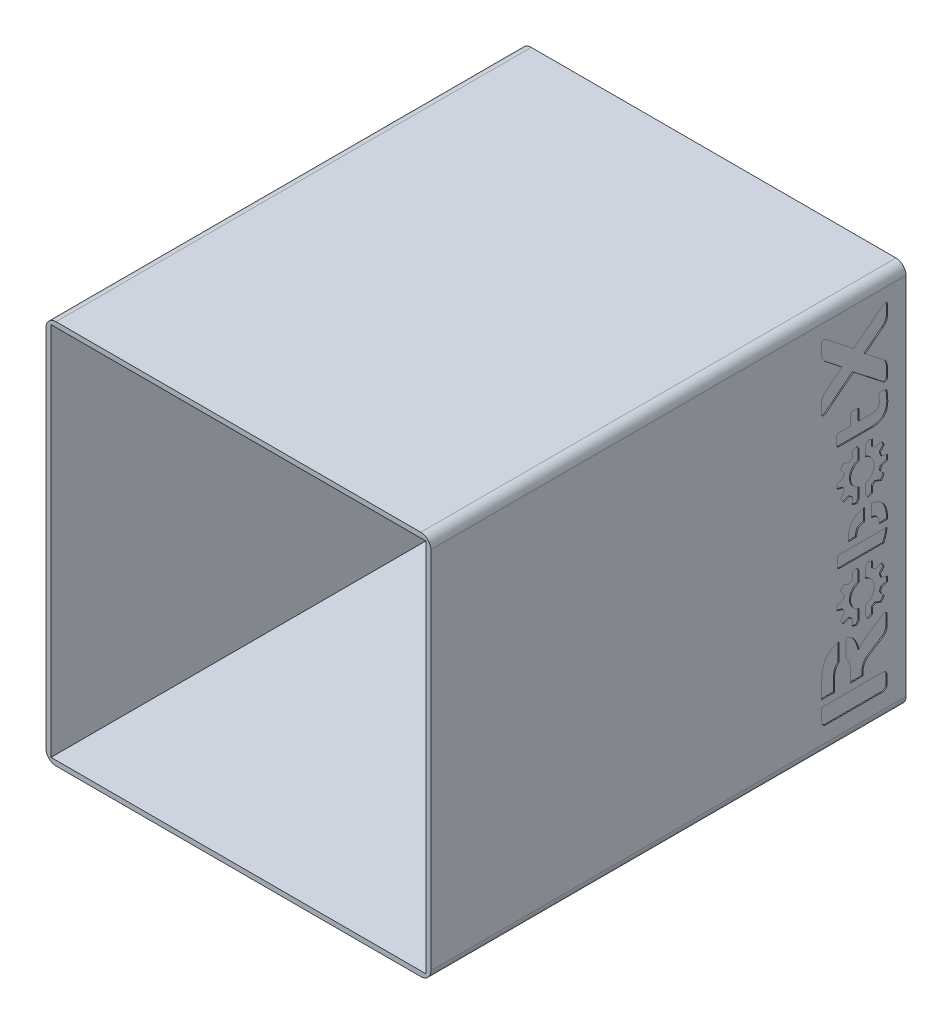
from build123d import *

# Parameters (mm, degrees)
SKETCH_1_W          = 115
SKETCH_1_H          = 115
EXTRUDE_1_DEPTH     = 2
SKETCH_2_W          = 115
SKETCH_2_H          = 115
SKETCH_2_W_2        = 112
SKETCH_2_H_2        = 112
EXTRUDE_2_DEPTH     = 140
FILLET_1_R          = 3
CUT_EXTRUDE_1_DEPTH = 0.3


with BuildPart() as part:
    # Эскиз1 → Бобышка-Вытянуть1 (new body)
    with BuildSketch(Plane.XY):
        Rectangle(SKETCH_1_W, SKETCH_1_H)
    extrude(amount=EXTRUDE_1_DEPTH)

    # Эскиз2 → Бобышка-Вытянуть2 (add)
    with BuildSketch(Plane.XY.offset(2)):
        Rectangle(SKETCH_2_W, SKETCH_2_H)
        Rectangle(SKETCH_2_W_2, SKETCH_2_H_2, mode=Mode.SUBTRACT)
    extrude(amount=EXTRUDE_2_DEPTH)

    # Скругление1
    fillet_1_edges = [part.edges().sort_by_distance(p)[0] for p in [
        (57.5, -57.5, 71),
        (-57.5, -57.5, 71),
        (-57.5, 57.5, 71),
        (57.5, 57.5, 71),
    ]]
    fillet(fillet_1_edges, radius=FILLET_1_R)

    # Эскиз3 → Вырез-Вытянуть1 (cut)
    with BuildSketch(Plane(origin=(57.5, 0, 0), x_dir=(0, 0, -1), z_dir=(1, 0, 0))):
        with BuildLine():
            Line((-11.080562605, -38.273823271), (-6.969637498, -35.678999813))
            ThreePointArc((-6.969637498, -35.678999813), (-6.018819324, -34.670187292), (-5.673247782, -33.327675388))
            Line((-5.673247782, -33.327675388), (-5.673247782, -30.246101875))
            ThreePointArc((-5.673247782, -30.246101875), (-6.015820413, -29.666035895), (-6.689196543, -29.685964145))
            Line((-6.689196543, -29.685964145), (-10.877080493, -32.329364165))
            add(Edge.make_bspline(
                [(-10.877080493, -32.329364165), (-12.633193827, -33.437826119), (-13.609384525, -34.270049482), (-14.029837494, -35.409873863)],
                knots=[0.333333333, 0.333333333, 0.333333333, 0.333333333, 0.388888889, 0.388888889, 0.388888889, 0.388888889], degree=3))
            add(Edge.make_bspline(
                [(-17.988875381, -30.371318738), (-16.275658731, -30.693081088), (-14.839974018, -31.958272247), (-14.029837494, -35.409873863)],
                knots=[0.637571884, 0.637571884, 0.637571884, 0.637571884, 1, 1, 1, 1], degree=3))
            Line((-17.988875381, -30.371318738), (-17.988875381, -35.769994881))
            add(Edge.make_bspline(
                [(-17.988875381, -35.769994881), (-17.227109916, -36.290354954), (-16.637413678, -37.373701833), (-16.637413678, -38.952390091)],
                knots=[0.645896495, 0.645896495, 0.645896495, 0.645896495, 1, 1, 1, 1], degree=3))
            Line((-16.637413678, -38.952390091), (-16.637413678, -42.740580699))
            Line((-16.637413678, -42.740580699), (-12.809082226, -42.740580699))
            Line((-12.809082226, -42.740580699), (-12.809082226, -41.408922505))
            ThreePointArc((-12.809082226, -41.408922505), (-12.34832017, -39.618906633), (-11.080562605, -38.273823271))
        make_face()
        with BuildLine():
            Line((-25.180573226, -37.377711774), (-25.180573226, -42.740580699))
            Line((-25.180573226, -42.740580699), (-21.340337084, -42.740580699))
            Line((-21.340337084, -42.740580699), (-21.340337084, -38.952390091))
            add(Edge.make_bspline(
                [(-21.340337084, -38.952390091), (-21.340337084, -37.193873781), (-20.750640847, -36.121732081), (-19.988875381, -35.668319344)],
                knots=[0, 0, 0, 0, 0.354103505, 0.354103505, 0.354103505, 0.354103505], degree=3))
            Line((-19.988875381, -35.668319344), (-19.988875381, -30.34974922))
            add(Edge.make_bspline(
                [(-25.180573226, -37.377711774), (-25.180573226, -32.621234164), (-22.556371402, -30.71701754), (-19.988875381, -30.34974922)],
                knots=[0, 0, 0, 0, 0.50309199, 0.50309199, 0.50309199, 0.50309199], degree=3))
        make_face()
        with BuildLine():
            Line((-23.900284426, -49.860907913), (-6.953536582, -49.860907913))
            ThreePointArc((-6.953536582, -49.860907913), (-6.04823569, -49.485920005), (-5.673247782, -48.580619113))
            Line((-5.673247782, -48.580619113), (-5.673247782, -46.020869499))
            ThreePointArc((-5.673247782, -46.020869499), (-6.04823569, -45.115568606), (-6.953536582, -44.740580699))
            Line((-6.953536582, -44.740580699), (-25.180573226, -44.740580699))
            Line((-25.180573226, -44.740580699), (-25.180573226, -48.580619113))
            ThreePointArc((-25.180573226, -48.580619113), (-24.805585319, -49.485920005), (-23.900284426, -49.860907913))
        make_face()
        with BuildLine():
            Line((-5.630369109, -7.828075043), (-19.895761032, -7.828075043))
            add(Edge.make_bspline(
                [(-19.895761032, -7.828075043), (-20.259172738, -7.828075043), (-20.537907428, -8.103287703), (-20.537907428, -8.463152663)],
                knots=[0.545454545, 0.545454545, 0.545454545, 0.545454545, 0.636363636, 0.636363636, 0.636363636, 0.636363636], degree=3))
            Line((-20.537907428, -8.463152663), (-20.537907428, -10.770638423))
            add(Edge.make_bspline(
                [(-20.537907428, -10.770638423), (-20.537907428, -11.130503383), (-20.259172738, -11.405716043), (-19.895761032, -11.405716043)],
                knots=[0.727272727, 0.727272727, 0.727272727, 0.727272727, 0.818181818, 0.818181818, 0.818181818, 0.818181818], degree=3))
            Line((-19.895761032, -11.405716043), (-6.65077794, -11.405716043))
            add(Edge.make_bspline(
                [(-6.65077794, -11.405716043), (-6.215461864, -10.651151236), (-5.829871458, -9.269987246), (-5.630369109, -7.828075043)],
                knots=[0, 0, 0, 0, 0.06231394, 0.06231394, 0.06231394, 0.06231394], degree=3))
        make_face()
        with BuildLine():
            Line((-6.302331772, 28.133346575), (-7.41919838, 28.133346575))
            add(Edge.make_bspline(
                [(-7.41919838, 28.133346575), (-7.784340206, 28.133346575), (-8.063556858, 27.854092849), (-8.063556858, 27.488988097)],
                knots=[0.1, 0.1, 0.1, 0.1, 0.15, 0.15, 0.15, 0.15], degree=3))
            Line((-8.063556858, 27.488988097), (-8.063556858, 27.102380425))
            add(Edge.make_bspline(
                [(-8.063556858, 27.102380425), (-8.063556858, 26.629847579), (-7.934675276, 26.221749345), (-7.934675276, 25.663316041)],
                knots=[0.2, 0.2, 0.2, 0.2, 0.25, 0.25, 0.25, 0.25], degree=3))
            add(Edge.make_bspline(
                [(-7.934675276, 25.663316041), (-7.934675276, 24.567915279), (-8.707915336, 23.816165781), (-10.168470282, 23.816165781)],
                knots=[0.25, 0.25, 0.25, 0.25, 0.3, 0.3, 0.3, 0.3], degree=3))
            Line((-10.168470282, 23.816165781), (-14.01311823, 23.816165781))
            Line((-14.01311823, 23.816165781), (-14.01311823, 26.737238599))
            add(Edge.make_bspline(
                [(-14.01311823, 26.737238599), (-14.01311823, 27.102380425), (-14.292334882, 27.381597077), (-14.657476708, 27.381597077)],
                knots=[0.4, 0.4, 0.4, 0.4, 0.45, 0.45, 0.45, 0.45], degree=3))
            Line((-14.657476708, 27.381597077), (-15.903224898, 27.381597077))
            add(Edge.make_bspline(
                [(-15.903224898, 27.381597077), (-16.268366724, 27.381597077), (-16.547583376, 27.102380425), (-16.547583376, 26.737238599)],
                knots=[0.5, 0.5, 0.5, 0.5, 0.55, 0.55, 0.55, 0.55], degree=3))
            Line((-16.547583376, 26.737238599), (-16.547583376, 23.816165781))
            Line((-16.547583376, 23.816165781), (-20.066474444, 23.816165781))
            add(Edge.make_bspline(
                [(-20.066474444, 23.816165781), (-20.431628628, 23.816165781), (-20.7144291, 23.536912055), (-20.7144291, 23.171807303)],
                knots=[0.65, 0.65, 0.65, 0.65, 0.7, 0.7, 0.7, 0.7], degree=3))
            Line((-20.7144291, 23.171807303), (-20.7144291, 20.830621277))
            add(Edge.make_bspline(
                [(-20.7144291, 20.830621277), (-20.7144291, 20.465504167), (-20.431628628, 20.186287515), (-20.066474444, 20.186287515)],
                knots=[0.75, 0.75, 0.75, 0.75, 0.8, 0.8, 0.8, 0.8], degree=3))
            Line((-20.066474444, 20.186287515), (-10.168470282, 20.186287515))
            add(Edge.make_bspline(
                [(-10.168470282, 20.186287515), (-6.94669025, 20.186287515), (-5.443191254, 21.689798869), (-5.443191254, 24.696759787)],
                knots=[0.85, 0.85, 0.85, 0.85, 0.9, 0.9, 0.9, 0.9], degree=3))
            add(Edge.make_bspline(
                [(-5.443191254, 24.696759787), (-5.443191254, 25.663316041), (-5.529091712, 26.844617261), (-5.657973294, 27.488988097)],
                knots=[0.9, 0.9, 0.9, 0.9, 1, 1, 1, 1], degree=3))
            add(Edge.make_bspline(
                [(-5.657973294, 27.488988097), (-5.722407906, 27.854092849), (-5.980133996, 28.133346575), (-6.302331772, 28.133346575)],
                knots=[0, 0, 0, 0, 0.05, 0.05, 0.05, 0.05], degree=3))
        make_face()
        with BuildLine():
            Line((-25.2170664, 34.192399827), (-25.2170664, 31.250318409))
            add(Edge.make_bspline(
                [(-25.2170664, 31.250318409), (-25.2170664, 30.521826667), (-24.59595332, 30.241646091), (-23.923480392, 30.773991657)],
                knots=[0.095238095, 0.095238095, 0.095238095, 0.095238095, 0.142857143, 0.142857143, 0.142857143, 0.142857143], degree=3))
            Line((-23.923480392, 30.773991657), (-15.676406166, 37.274534459))
            Line((-15.676406166, 37.274534459), (-6.868908998, 30.381736379))
            add(Edge.make_bspline(
                [(-6.868908998, 30.381736379), (-6.196460786, 29.849341381), (-5.575347706, 30.129559031), (-5.575347706, 30.858063131)],
                knots=[0.238095238, 0.238095238, 0.238095238, 0.238095238, 0.285714286, 0.285714286, 0.285714286, 0.285714286], degree=3))
            Line((-5.575347706, 30.858063131), (-5.575347706, 33.772091889))
            add(Edge.make_bspline(
                [(-5.575347706, 33.772091889), (-5.575347706, 34.892888341), (-6.196460786, 35.621392441), (-6.868908998, 36.153738007)],
                knots=[0.333333333, 0.333333333, 0.333333333, 0.333333333, 0.380952381, 0.380952381, 0.380952381, 0.380952381], degree=3))
            Line((-6.868908998, 36.153738007), (-12.197320216, 40.328653505))
            Line((-12.197320216, 40.328653505), (-6.868908998, 44.503569003))
            add(Edge.make_bspline(
                [(-6.868908998, 44.503569003), (-6.196460786, 45.035964001), (-5.575347706, 45.764455743), (-5.575347706, 46.885252195)],
                knots=[0.476190476, 0.476190476, 0.476190476, 0.476190476, 0.523809524, 0.523809524, 0.523809524, 0.523809524], degree=3))
            Line((-5.575347706, 46.885252195), (-5.575347706, 49.799293311))
            add(Edge.make_bspline(
                [(-5.575347706, 49.799293311), (-5.575347706, 50.527785053), (-6.196460786, 50.807965629), (-6.868908998, 50.275620063)],
                knots=[0.571428571, 0.571428571, 0.571428571, 0.571428571, 0.619047619, 0.619047619, 0.619047619, 0.619047619], degree=3))
            Line((-6.868908998, 50.275620063), (-15.676406166, 43.382809625))
            Line((-15.676406166, 43.382809625), (-23.923480392, 49.883352427))
            add(Edge.make_bspline(
                [(-23.923480392, 49.883352427), (-24.59595332, 50.415710351), (-25.2170664, 50.135529775), (-25.2170664, 49.406988601)],
                knots=[0.714285714, 0.714285714, 0.714285714, 0.714285714, 0.761904762, 0.761904762, 0.761904762, 0.761904762], degree=3))
            Line((-25.2170664, 49.406988601), (-25.2170664, 46.464944257))
            add(Edge.make_bspline(
                [(-25.2170664, 46.464944257), (-25.2170664, 45.344184879), (-24.59595332, 44.615656063), (-23.923480392, 44.083298139)],
                knots=[0.80952381, 0.80952381, 0.80952381, 0.80952381, 0.857142857, 0.857142857, 0.857142857, 0.857142857], degree=3))
            Line((-23.923480392, 44.083298139), (-19.155492116, 40.328653505))
            Line((-19.155492116, 40.328653505), (-23.923480392, 36.574045945))
            add(Edge.make_bspline(
                [(-23.923480392, 36.574045945), (-24.59595332, 36.041663305), (-25.2170664, 35.313159205), (-25.2170664, 34.192399827)],
                knots=[0, 0, 0, 0, 0.047619048, 0.047619048, 0.047619048, 0.047619048], degree=3))
        make_face()
        with BuildLine():
            Line((-11.414839648, 17.557769467), (-12.038698502, 16.632133342))
            Line((-12.038698502, 16.632133342), (-12.038698502, 13.562056879))
            ThreePointArc((-12.038698502, 13.562056879), (-9.495381339, 10.162778055), (-12.038698502, 6.763499231))
            Line((-12.038698502, 6.763499231), (-12.038698502, 3.693422768))
            Line((-12.038698502, 3.693422768), (-11.414839648, 2.767786643))
            ThreePointArc((-11.414839648, 2.767786643), (-10.699074215, 2.962154904), (-10.005761019, 3.225624043))
            Line((-10.005761019, 3.225624043), (-10.072668169, 5.121785023))
            ThreePointArc((-10.072668169, 5.121785023), (-9.600835735, 5.430965898), (-9.160983009, 5.784163064))
            Line((-9.160983009, 5.784163064), (-7.3783022, 5.134584616))
            ThreePointArc((-7.3783022, 5.134584616), (-6.913482598, 5.712548208), (-6.507443714, 6.333218491))
            Line((-6.507443714, 6.333218491), (-7.676108195, 7.827917911))
            ThreePointArc((-7.676108195, 7.827917911), (-7.476119697, 8.355386639), (-7.327875451, 8.899668095))
            Line((-7.327875451, 8.899668095), (-5.503843749, 9.42198158))
            ThreePointArc((-5.503843749, 9.42198158), (-5.467515268, 10.162778055), (-5.503843749, 10.90357453))
            Line((-5.503843749, 10.90357453), (-7.327875451, 11.425888016))
            ThreePointArc((-7.327875451, 11.425888016), (-7.476119697, 11.970169471), (-7.676108195, 12.497638199))
            Line((-7.676108195, 12.497638199), (-6.507443714, 13.992337619))
            ThreePointArc((-6.507443714, 13.992337619), (-6.913482598, 14.613007902), (-7.3783022, 15.190971494))
            Line((-7.3783022, 15.190971494), (-9.160983009, 14.541393047))
            ThreePointArc((-9.160983009, 14.541393047), (-9.600835735, 14.894590212), (-10.072668169, 15.203771087))
            Line((-10.072668169, 15.203771087), (-10.005761019, 17.099932067))
            ThreePointArc((-10.005761019, 17.099932067), (-10.699074215, 17.363401206), (-11.414839648, 17.557769467))
        make_face()
        with BuildLine():
            Line((-20.573553255, 9.42198158), (-18.749521553, 8.899668095))
            ThreePointArc((-18.749521553, 8.899668095), (-18.601277307, 8.355386639), (-18.401288809, 7.827917911))
            Line((-18.401288809, 7.827917911), (-19.56995329, 6.333218491))
            ThreePointArc((-19.56995329, 6.333218491), (-19.163914406, 5.712548208), (-18.699094804, 5.134584616))
            Line((-18.699094804, 5.134584616), (-16.916413995, 5.784163064))
            ThreePointArc((-16.916413995, 5.784163064), (-16.476561269, 5.430965898), (-16.004728835, 5.121785023))
            Line((-16.004728835, 5.121785023), (-16.071635986, 3.225624043))
            ThreePointArc((-16.071635986, 3.225624043), (-15.378322789, 2.962154904), (-14.662557356, 2.767786643))
            Line((-14.662557356, 2.767786643), (-14.038698502, 3.693422768))
            Line((-14.038698502, 3.693422768), (-14.038698502, 6.763499231))
            ThreePointArc((-14.038698502, 6.763499231), (-16.582015666, 10.162778055), (-14.038698502, 13.562056879))
            Line((-14.038698502, 13.562056879), (-14.038698502, 16.632133342))
            Line((-14.038698502, 16.632133342), (-14.662557356, 17.557769467))
            ThreePointArc((-14.662557356, 17.557769467), (-15.378322789, 17.363401206), (-16.071635986, 17.099932067))
            Line((-16.071635986, 17.099932067), (-16.004728835, 15.203771087))
            ThreePointArc((-16.004728835, 15.203771087), (-16.476561269, 14.894590212), (-16.916413995, 14.541393047))
            Line((-16.916413995, 14.541393047), (-18.699094804, 15.190971494))
            ThreePointArc((-18.699094804, 15.190971494), (-19.163914406, 14.613007902), (-19.56995329, 13.992337619))
            Line((-19.56995329, 13.992337619), (-18.401288809, 12.497638199))
            ThreePointArc((-18.401288809, 12.497638199), (-18.601277307, 11.970169471), (-18.749521553, 11.425888016))
            Line((-18.749521553, 11.425888016), (-20.573553255, 10.90357453))
            ThreePointArc((-20.573553255, 10.90357453), (-20.609881736, 10.162778055), (-20.573553255, 9.42198158))
        make_face()
        with BuildLine():
            Line((-5.486491136, -5.828075043), (-7.985961501, -5.828075043))
            add(Edge.make_bspline(
                [(-7.9844533, -5.64764188), (-7.9844533, -5.70802445), (-7.984965535, -5.768202102), (-7.985961501, -5.828075043)],
                knots=[0.5, 0.5, 0.5, 0.5, 0.511595005, 0.511595005, 0.511595005, 0.511595005], degree=3))
            add(Edge.make_bspline(
                [(-10.350389402, -3.033887505), (-8.722309547, -3.230253628), (-7.9844533, -3.987209795), (-7.9844533, -5.64764188)],
                knots=[0.359434534, 0.359434534, 0.359434534, 0.359434534, 0.5, 0.5, 0.5, 0.5], degree=3))
            Line((-10.350389402, -3.033887505), (-10.350389402, 0.649260356))
            add(Edge.make_bspline(
                [(-6.318273592, -1.879687681), (-7.108463161, -0.412906163), (-8.457955871, 0.43549702), (-10.350389402, 0.649260356)],
                knots=[0.181818182, 0.181818182, 0.181818182, 0.181818182, 0.25964789, 0.25964789, 0.25964789, 0.25964789], degree=3))
            add(Edge.make_bspline(
                [(-5.486491136, -5.828075043), (-5.490052591, -4.216962711), (-5.769147793, -2.898950721), (-6.318273592, -1.879687681)],
                knots=[0.091492811, 0.091492811, 0.091492811, 0.091492811, 0.181818182, 0.181818182, 0.181818182, 0.181818182], degree=3))
        make_face()
        with BuildLine():
            Line((-16.071635986, -14.372039935), (-16.004728835, -16.268200915))
            ThreePointArc((-16.004728835, -16.268200915), (-16.476561269, -16.57738179), (-16.916413995, -16.930578956))
            Line((-16.916413995, -16.930578956), (-18.699094804, -16.281000508))
            ThreePointArc((-18.699094804, -16.281000508), (-19.163914406, -16.8589641), (-19.56995329, -17.479634383))
            Line((-19.56995329, -17.479634383), (-18.401288809, -18.974333803))
            ThreePointArc((-18.401288809, -18.974333803), (-18.601277307, -19.501802532), (-18.749521553, -20.046083987))
            Line((-18.749521553, -20.046083987), (-20.573553255, -20.568397472))
            ThreePointArc((-20.573553255, -20.568397472), (-20.609881736, -21.309193947), (-20.573553255, -22.049990422))
            Line((-20.573553255, -22.049990422), (-18.749521553, -22.572303908))
            ThreePointArc((-18.749521553, -22.572303908), (-18.601277307, -23.116585363), (-18.401288809, -23.644054091))
            Line((-18.401288809, -23.644054091), (-19.56995329, -25.138753511))
            ThreePointArc((-19.56995329, -25.138753511), (-19.163914406, -25.759423794), (-18.699094804, -26.337387387))
            Line((-18.699094804, -26.337387387), (-16.916413995, -25.687808939))
            ThreePointArc((-16.916413995, -25.687808939), (-16.476561269, -26.041006104), (-16.004728835, -26.35018698))
            Line((-16.004728835, -26.35018698), (-16.071635986, -28.246347959))
            ThreePointArc((-16.071635986, -28.246347959), (-15.378322789, -28.509817098), (-14.662557356, -28.704185359))
            Line((-14.662557356, -28.704185359), (-14.038698502, -27.778549234))
            Line((-14.038698502, -27.778549234), (-14.038698502, -24.708472771))
            ThreePointArc((-14.038698502, -24.708472771), (-16.582015666, -21.309193947), (-14.038698502, -17.909915123))
            Line((-14.038698502, -17.909915123), (-14.038698502, -14.839838661))
            Line((-14.038698502, -14.839838661), (-14.662557356, -13.914202535))
            ThreePointArc((-14.662557356, -13.914202535), (-15.378322789, -14.108570796), (-16.071635986, -14.372039935))
        make_face()
        with BuildLine():
            Line((-12.350389402, -3.032641726), (-12.350389402, 0.650109703))
            add(Edge.make_bspline(
                [(-12.350389402, 0.650109703), (-15.585801374, 0.293035227), (-17.235479088, -1.836360179), (-17.235479088, -4.843222586)],
                knots=[0.280863598, 0.280863598, 0.280863598, 0.280863598, 0.363636364, 0.363636364, 0.363636364, 0.363636364], degree=3))
            add(Edge.make_bspline(
                [(-17.235479088, -4.843222586), (-17.235479088, -5.201939023), (-17.215217395, -5.526884984), (-17.179939166, -5.828075043)],
                knots=[0.363636364, 0.363636364, 0.363636364, 0.363636364, 0.389310851, 0.389310851, 0.389310851, 0.389310851], degree=3))
            Line((-17.179939166, -5.828075043), (-14.728571204, -5.828075043))
            add(Edge.make_bspline(
                [(-14.728571204, -5.828075043), (-14.734491804, -5.74091941), (-14.7374824, -5.659322536), (-14.7374824, -5.584134118)],
                knots=[0.142988723, 0.142988723, 0.142988723, 0.142988723, 0.166666667, 0.166666667, 0.166666667, 0.166666667], degree=3))
            add(Edge.make_bspline(
                [(-14.7374824, -5.584134118), (-14.7374824, -3.974499399), (-13.997111465, -3.226122763), (-12.350389402, -3.032641726)],
                knots=[0.166666667, 0.166666667, 0.166666667, 0.166666667, 0.307473976, 0.307473976, 0.307473976, 0.307473976], degree=3))
        make_face()
        with BuildLine():
            Line((-10.005761019, -28.246347959), (-10.072668169, -26.35018698))
            ThreePointArc((-10.072668169, -26.35018698), (-9.600835735, -26.041006104), (-9.160983009, -25.687808939))
            Line((-9.160983009, -25.687808939), (-7.3783022, -26.337387387))
            ThreePointArc((-7.3783022, -26.337387387), (-6.913482598, -25.759423794), (-6.507443714, -25.138753511))
            Line((-6.507443714, -25.138753511), (-7.676108195, -23.644054091))
            ThreePointArc((-7.676108195, -23.644054091), (-7.476119697, -23.116585363), (-7.327875451, -22.572303908))
            Line((-7.327875451, -22.572303908), (-5.503843749, -22.049990422))
            ThreePointArc((-5.503843749, -22.049990422), (-5.467515268, -21.309193947), (-5.503843749, -20.568397472))
            Line((-5.503843749, -20.568397472), (-7.327875451, -20.046083987))
            ThreePointArc((-7.327875451, -20.046083987), (-7.476119697, -19.501802532), (-7.676108195, -18.974333803))
            Line((-7.676108195, -18.974333803), (-6.507443714, -17.479634383))
            ThreePointArc((-6.507443714, -17.479634383), (-6.913482598, -16.8589641), (-7.3783022, -16.281000508))
            Line((-7.3783022, -16.281000508), (-9.160983009, -16.930578956))
            ThreePointArc((-9.160983009, -16.930578956), (-9.600835735, -16.57738179), (-10.072668169, -16.268200915))
            Line((-10.072668169, -16.268200915), (-10.005761019, -14.372039935))
            ThreePointArc((-10.005761019, -14.372039935), (-10.699074215, -14.108570796), (-11.414839648, -13.914202535))
            Line((-11.414839648, -13.914202535), (-12.038698502, -14.839838661))
            Line((-12.038698502, -14.839838661), (-12.038698502, -17.909915123))
            ThreePointArc((-12.038698502, -17.909915123), (-9.495381339, -21.309193947), (-12.038698502, -24.708472771))
            Line((-12.038698502, -24.708472771), (-12.038698502, -27.778549234))
            Line((-12.038698502, -27.778549234), (-11.414839648, -28.704185359))
            ThreePointArc((-11.414839648, -28.704185359), (-10.699074215, -28.509817098), (-10.005761019, -28.246347959))
        make_face()
    extrude(amount=-CUT_EXTRUDE_1_DEPTH, mode=Mode.SUBTRACT)


solid = part.part
